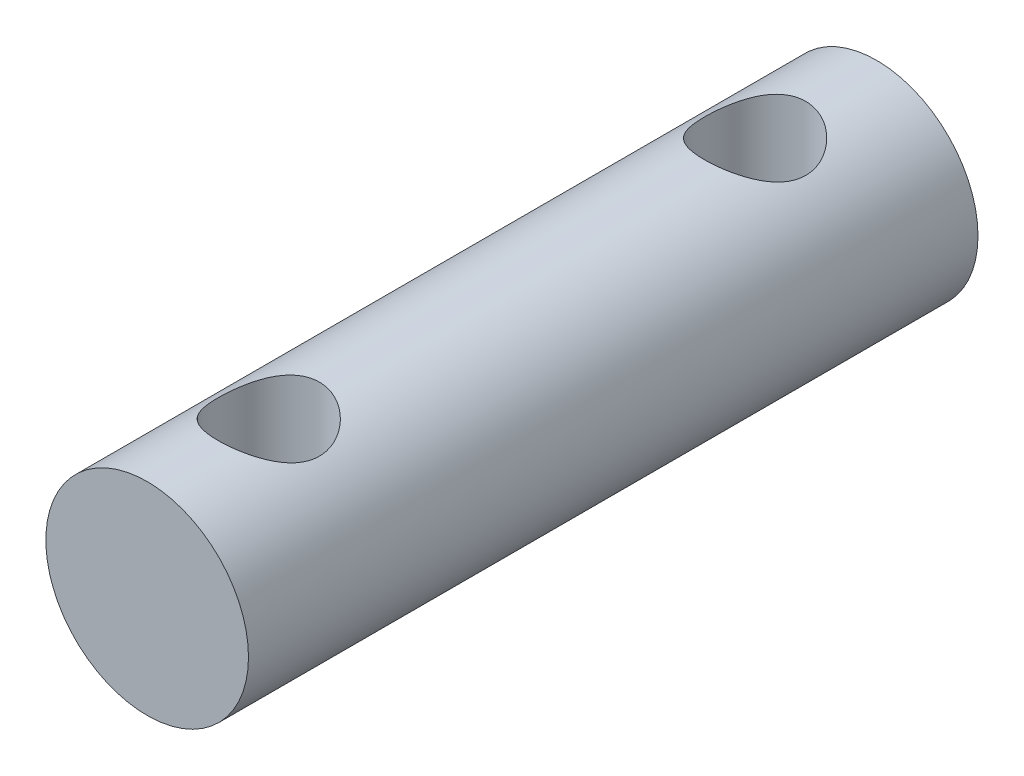
from build123d import *

# Parameters (mm, degrees)
SKETCH1_R               = 2.5
BOSS_EXTRUDE1_DEPTH     = 18
SKETCH2_R               = 1.25
CUT_EXTRUDE1_DEPTH      = 3.5
CUT_EXTRUDE1_DEPTH_BACK = 3.5


with BuildPart() as part:
    # Sketch1 → Boss-Extrude1 (new body)
    with BuildSketch(Plane.XY):
        Circle(SKETCH1_R)
    extrude(amount=BOSS_EXTRUDE1_DEPTH)

    # Sketch2 → Cut-Extrude1 (cut, two sides)
    with BuildSketch(Plane(origin=(0, 0, 0), x_dir=(1, 0, 0), z_dir=(0, 1, 0))) as cut_extrude1_sk:
        with Locations((0, -3)):
            Circle(SKETCH2_R)
        with Locations((0, -15)):
            Circle(SKETCH2_R)
    extrude(amount=CUT_EXTRUDE1_DEPTH, mode=Mode.SUBTRACT)
    extrude(cut_extrude1_sk.sketch, amount=-CUT_EXTRUDE1_DEPTH_BACK, mode=Mode.SUBTRACT)


solid = part.part
